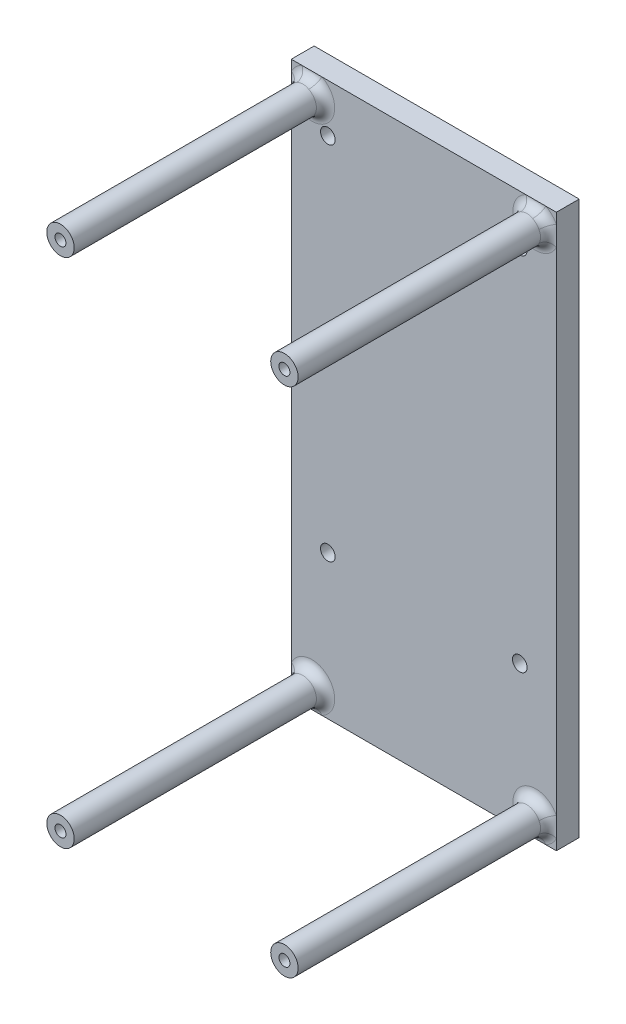
from build123d import *

# Parameters (mm, degrees)
SCHIZZO1_W                   = 58
SCHIZZO1_H                   = 121
ESTRUSIONE_ESTRUSIONE2_DEPTH = 5
TAGLIO_ESTRUSIONE1_REACH     = 7
SCHIZZO12_R                  = 1.6
SCHIZZO2_R                   = 3
ESTRUSIONE_ESTRUSIONE3_DEPTH = 55
RACCORDO1_R                  = 2
FORO_PER_VITE_M3_1_D         = 2.4
FORO_PER_VITE_M3_1_DEPTH     = 20
FORO_PER_VITE_M3_1_TIP       = 0.721032743


with BuildPart() as part:
    # Schizzo1 → Estrusione-Estrusione2 (new body)
    with BuildSketch(Plane.XY):
        with Locations((115.836484846, -73.380424615)):
            Rectangle(SCHIZZO1_W, SCHIZZO1_H)
    extrude(amount=ESTRUSIONE_ESTRUSIONE2_DEPTH)

    # Schizzo12 → Taglio-Estrusione1 (cut, up to next)
    with BuildSketch(Plane(origin=(0, 0, 0), x_dir=(-1, 0, 0), z_dir=(0, 0, -1)), mode=Mode.PRIVATE) as taglio_estrusione1_sk1:
        with Locations((-94.836484846, -102.380424615)):
            Circle(SCHIZZO12_R)
    taglio_estrusione1_tool1 = extrude(taglio_estrusione1_sk1.sketch, amount=-TAGLIO_ESTRUSIONE1_REACH, mode=Mode.PRIVATE) & part.part
    add(taglio_estrusione1_tool1.solids().sort_by_distance((94.836485, -102.380425, 0))[0], mode=Mode.SUBTRACT)
    # Schizzo12 → Taglio-Estrusione1 (cut, up to next)
    with BuildSketch(Plane(origin=(0, 0, 0), x_dir=(-1, 0, 0), z_dir=(0, 0, -1)), mode=Mode.PRIVATE) as taglio_estrusione1_sk2:
        with Locations((-136.836484846, -102.380424615)):
            Circle(SCHIZZO12_R)
    taglio_estrusione1_tool2 = extrude(taglio_estrusione1_sk2.sketch, amount=-TAGLIO_ESTRUSIONE1_REACH, mode=Mode.PRIVATE) & part.part
    add(taglio_estrusione1_tool2.solids().sort_by_distance((136.836485, -102.380425, 0))[0], mode=Mode.SUBTRACT)
    # Schizzo12 → Taglio-Estrusione1 (cut, up to next)
    with BuildSketch(Plane(origin=(0, 0, 0), x_dir=(-1, 0, 0), z_dir=(0, 0, -1)), mode=Mode.PRIVATE) as taglio_estrusione1_sk3:
        with Locations((-136.836484846, -23.380424615)):
            Circle(SCHIZZO12_R)
    taglio_estrusione1_tool3 = extrude(taglio_estrusione1_sk3.sketch, amount=-TAGLIO_ESTRUSIONE1_REACH, mode=Mode.PRIVATE) & part.part
    add(taglio_estrusione1_tool3.solids().sort_by_distance((136.836485, -23.380425, 0))[0], mode=Mode.SUBTRACT)
    # Schizzo12 → Taglio-Estrusione1 (cut, up to next)
    with BuildSketch(Plane(origin=(0, 0, 0), x_dir=(-1, 0, 0), z_dir=(0, 0, -1)), mode=Mode.PRIVATE) as taglio_estrusione1_sk4:
        with Locations((-94.836484846, -23.380424615)):
            Circle(SCHIZZO12_R)
    taglio_estrusione1_tool4 = extrude(taglio_estrusione1_sk4.sketch, amount=-TAGLIO_ESTRUSIONE1_REACH, mode=Mode.PRIVATE) & part.part
    add(taglio_estrusione1_tool4.solids().sort_by_distance((94.836485, -23.380425, 0))[0], mode=Mode.SUBTRACT)

    # Schizzo2 → Estrusione-Estrusione3 (add)
    with BuildSketch(Plane.XY.offset(5)):
        with Locations((140.336484846, -129.380424615)):
            Circle(SCHIZZO2_R)
        with Locations((91.336484846, -129.380424615)):
            Circle(SCHIZZO2_R)
        with Locations((140.336484846, -17.380424615)):
            Circle(SCHIZZO2_R)
        with Locations((91.336484846, -17.380424615)):
            Circle(SCHIZZO2_R)
    extrude(amount=ESTRUSIONE_ESTRUSIONE3_DEPTH)

    # Raccordo1
    raccordo1_edges = [part.edges().sort_by_distance(p)[0] for p in [
        (88.336484846, -129.380424615, 5),
        (137.336484846, -17.380424615, 5),
        (137.336484846, -129.380424615, 5),
        (88.336484846, -17.380424615, 5),
    ]]
    fillet(raccordo1_edges, radius=RACCORDO1_R)

    # Foro per Vite M3-1
    with Locations(Plane.XY.offset(60)):
        with Locations((140.336484846, -129.380424615), (91.336484846, -129.380424615), (91.336484846, -17.380424615), (140.336484846, -17.380424615)):
            Hole(FORO_PER_VITE_M3_1_D / 2, depth=FORO_PER_VITE_M3_1_DEPTH)
            with Locations((0, 0, -(FORO_PER_VITE_M3_1_DEPTH + FORO_PER_VITE_M3_1_TIP / 2))):  # 118° drill point
                Cone(0, FORO_PER_VITE_M3_1_D / 2, FORO_PER_VITE_M3_1_TIP, mode=Mode.SUBTRACT)


solid = part.part
